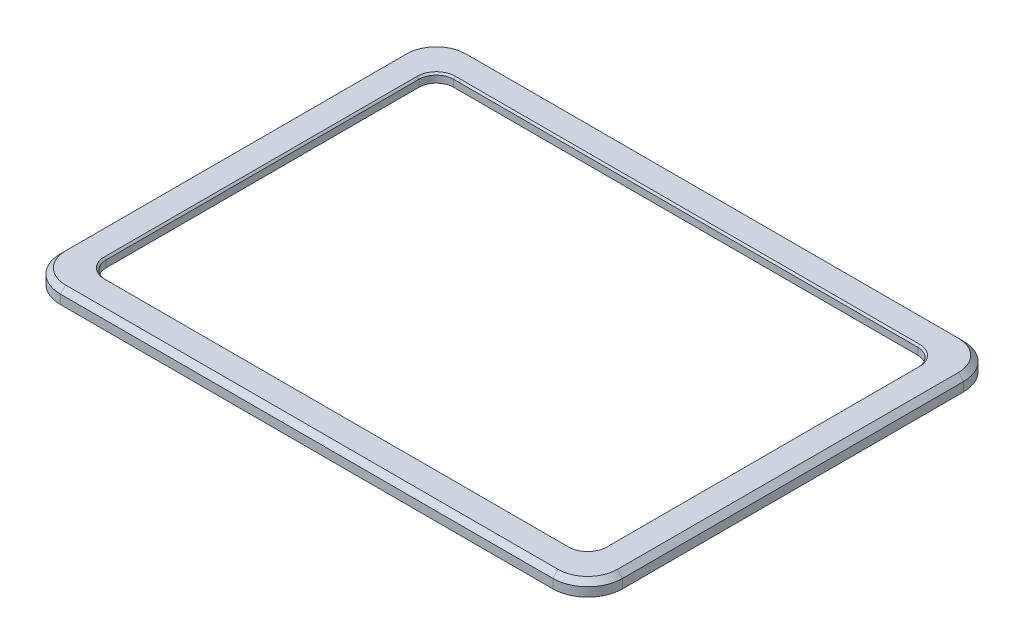
from build123d import *

# Parameters (mm, degrees)
SKETCH1_W                  = 323
SKETCH1_H                  = 236
SKETCH1_W_2                = 286.7
SKETCH1_H_2                = 199.7
BOSS_EXTRUDE1_DEPTH        = 5
SKETCH2_W                  = 323
SKETCH2_H                  = 236
SKETCH2_W_2                = 297.2
SKETCH2_H_2                = 210.2
BOSS_EXTRUDE2_DEPTH        = 3.2
FILLET1_R                  = 10
FILLET2_R                  = 20
M4_TAPPED_HOLE1_AT_2_COUNT = 2
M4_TAPPED_HOLE1_AT_2_PITCH = 66.8
M4_TAPPED_HOLE1_AT_3_COUNT = 2
M4_TAPPED_HOLE1_AT_3_PITCH = 133.6
M4_TAPPED_HOLE1_AT_4_COUNT = 2
M4_TAPPED_HOLE1_AT_4_PITCH = 200.4
M4_TAPPED_HOLE1_AT_5_COUNT = 2
M4_TAPPED_HOLE1_AT_5_PITCH = 267.2
M4_TAPPED_HOLE2_AT_2_COUNT = 2
M4_TAPPED_HOLE2_AT_2_PITCH = 45.05
M4_TAPPED_HOLE2_AT_3_COUNT = 2
M4_TAPPED_HOLE2_AT_3_PITCH = 90.1
M4_TAPPED_HOLE2_AT_4_COUNT = 2
M4_TAPPED_HOLE2_AT_4_PITCH = 135.15
M4_TAPPED_HOLE2_AT_5_COUNT = 2
M4_TAPPED_HOLE2_AT_5_PITCH = 180.2
CHAMFER2_SIZE              = 3
SKETCH7_R                  = 3
CUT_EXTRUDE1_DEPTH         = 3.2
FILLET3_R                  = 10
CHAMFER3_SIZE              = 1
CUT_EXTRUDE2_DEPTH         = 2
CUT_EXTRUDE3_DEPTH         = 2


with BuildPart() as part:
    # Sketch1 → Boss-Extrude1 (new body)
    with BuildSketch(Plane(origin=(0, 0, 0), x_dir=(1, 0, 0), z_dir=(0, 1, 0))):
        Rectangle(SKETCH1_W, SKETCH1_H)
        Rectangle(SKETCH1_W_2, SKETCH1_H_2, mode=Mode.SUBTRACT)
    extrude(amount=BOSS_EXTRUDE1_DEPTH)

    # Sketch2 → Boss-Extrude2 (add)
    with BuildSketch(Plane.XZ):
        Rectangle(SKETCH2_W, SKETCH2_H)
        Rectangle(SKETCH2_W_2, SKETCH2_H_2, mode=Mode.SUBTRACT)
    extrude(amount=BOSS_EXTRUDE2_DEPTH)

    # Fillet1
    fillet1_edges = [part.edges().sort_by_distance(p)[0] for p in [
        (-143.35, 2.5, 99.85),
        (143.35, 2.5, 99.85),
        (143.35, 2.5, -99.85),
        (-143.35, 2.5, -99.85),
    ]]
    fillet(fillet1_edges, radius=FILLET1_R)

    # Fillet2
    fillet2_edges = [part.edges().sort_by_distance(p)[0] for p in [
        (-161.5, 0.9, 118),
        (-161.5, 0.9, -118),
        (161.5, 0.9, -118),
        (161.5, 0.9, 118),
    ]]
    fillet(fillet2_edges, radius=FILLET2_R)

    # Sketch4 → M4 Tapped Hole1 (revolve, cut)
    with BuildSketch(Plane(origin=(133.6, -3.2, -109), x_dir=(0, 0, -1), z_dir=(1, 0, 0))):
        Polygon((0, 0), (0, 6.991420021), (1.65, 6), (1.65, 0), align=None)
    m4_tapped_hole1 = revolve(axis=Axis((133.6, -9.55, -109), (0, 1, 0)), mode=Mode.SUBTRACT)

    # M4 Tapped Hole1 at 2: M4 Tapped Hole1 ×2
    with Locations(*[(-i * M4_TAPPED_HOLE1_AT_2_PITCH, 0, 0) for i in range(1, M4_TAPPED_HOLE1_AT_2_COUNT)]):
        add(m4_tapped_hole1, mode=Mode.SUBTRACT)

    # M4 Tapped Hole1 at 3: M4 Tapped Hole1 ×2
    with Locations(*[(-i * M4_TAPPED_HOLE1_AT_3_PITCH, 0, 0) for i in range(1, M4_TAPPED_HOLE1_AT_3_COUNT)]):
        add(m4_tapped_hole1, mode=Mode.SUBTRACT)

    # M4 Tapped Hole1 at 4: M4 Tapped Hole1 ×2
    with Locations(*[(-i * M4_TAPPED_HOLE1_AT_4_PITCH, 0, 0) for i in range(1, M4_TAPPED_HOLE1_AT_4_COUNT)]):
        add(m4_tapped_hole1, mode=Mode.SUBTRACT)

    # M4 Tapped Hole1 at 5: M4 Tapped Hole1 ×2
    with Locations(*[(-i * M4_TAPPED_HOLE1_AT_5_PITCH, 0, 0) for i in range(1, M4_TAPPED_HOLE1_AT_5_COUNT)]):
        add(m4_tapped_hole1, mode=Mode.SUBTRACT)

    # Mirror1: M4 Tapped Hole1 across plane
    add(m4_tapped_hole1.mirror(Plane.XY), mode=Mode.SUBTRACT)

    # Mirror1 copy 1 sketch → Mirror1 copy 1 (revolve, cut)
    with BuildSketch(Plane(origin=(66.8, -3.2, 109), x_dir=(0, 0, 1), z_dir=(1, 0, 0))):
        Polygon((0, 0), (0, -6.991420021), (1.65, -6), (1.65, 0), align=None)
    revolve(axis=Axis((66.8, -9.55, 109), (0, -1, 0)), mode=Mode.SUBTRACT)

    # Mirror1 copy 2 sketch → Mirror1 copy 2 (revolve, cut)
    with BuildSketch(Plane(origin=(0, -3.2, 109), x_dir=(0, 0, 1), z_dir=(1, 0, 0))):
        Polygon((0, 0), (0, -6.991420021), (1.65, -6), (1.65, 0), align=None)
    revolve(axis=Axis((0, -9.55, 109), (0, -1, 0)), mode=Mode.SUBTRACT)

    # Mirror1 copy 3 sketch → Mirror1 copy 3 (revolve, cut)
    with BuildSketch(Plane(origin=(-66.8, -3.2, 109), x_dir=(0, 0, 1), z_dir=(1, 0, 0))):
        Polygon((0, 0), (0, -6.991420021), (1.65, -6), (1.65, 0), align=None)
    revolve(axis=Axis((-66.8, -9.55, 109), (0, -1, 0)), mode=Mode.SUBTRACT)

    # Mirror1 copy 4 sketch → Mirror1 copy 4 (revolve, cut)
    with BuildSketch(Plane(origin=(-133.6, -3.2, 109), x_dir=(0, 0, 1), z_dir=(1, 0, 0))):
        Polygon((0, 0), (0, -6.991420021), (1.65, -6), (1.65, 0), align=None)
    revolve(axis=Axis((-133.6, -9.55, 109), (0, -1, 0)), mode=Mode.SUBTRACT)

    # Sketch6 → M4 Tapped Hole2 (revolve, cut)
    with BuildSketch(Plane(origin=(152.5, -3.2, -90.1), x_dir=(0, 0, -1), z_dir=(1, 0, 0))):
        Polygon((0, 0), (0, 7.091420021), (1.65, 6.1), (1.65, 0), align=None)
    m4_tapped_hole2 = revolve(axis=Axis((152.5, -9.55, -90.1), (0, 1, 0)), mode=Mode.SUBTRACT)

    # M4 Tapped Hole2 at 2: M4 Tapped Hole2 ×2
    with Locations(*[(0, 0, i * M4_TAPPED_HOLE2_AT_2_PITCH) for i in range(1, M4_TAPPED_HOLE2_AT_2_COUNT)]):
        add(m4_tapped_hole2, mode=Mode.SUBTRACT)

    # M4 Tapped Hole2 at 3: M4 Tapped Hole2 ×2
    with Locations(*[(0, 0, i * M4_TAPPED_HOLE2_AT_3_PITCH) for i in range(1, M4_TAPPED_HOLE2_AT_3_COUNT)]):
        add(m4_tapped_hole2, mode=Mode.SUBTRACT)

    # M4 Tapped Hole2 at 4: M4 Tapped Hole2 ×2
    with Locations(*[(0, 0, i * M4_TAPPED_HOLE2_AT_4_PITCH) for i in range(1, M4_TAPPED_HOLE2_AT_4_COUNT)]):
        add(m4_tapped_hole2, mode=Mode.SUBTRACT)

    # M4 Tapped Hole2 at 5: M4 Tapped Hole2 ×2
    with Locations(*[(0, 0, i * M4_TAPPED_HOLE2_AT_5_PITCH) for i in range(1, M4_TAPPED_HOLE2_AT_5_COUNT)]):
        add(m4_tapped_hole2, mode=Mode.SUBTRACT)

    # Mirror2: M4 Tapped Hole2 across plane
    add(m4_tapped_hole2.mirror(Plane(origin=(0, 0, 0), x_dir=(0, 0, 1), z_dir=(1, 0, 0))), mode=Mode.SUBTRACT)

    # Mirror2 copy 1 sketch → Mirror2 copy 1 (revolve, cut)
    with BuildSketch(Plane(origin=(-152.5, -3.2, -45.05), x_dir=(0, 0, -1), z_dir=(-1, 0, 0))):
        Polygon((0, 0), (0, -7.091420021), (1.65, -6.1), (1.65, 0), align=None)
    revolve(axis=Axis((-152.5, -9.55, -45.05), (0, -1, 0)), mode=Mode.SUBTRACT)

    # Mirror2 copy 2 sketch → Mirror2 copy 2 (revolve, cut)
    with BuildSketch(Plane(origin=(-152.5, -3.2, 0), x_dir=(0, 0, -1), z_dir=(-1, 0, 0))):
        Polygon((0, 0), (0, -7.091420021), (1.65, -6.1), (1.65, 0), align=None)
    revolve(axis=Axis((-152.5, -9.55, 0), (0, -1, 0)), mode=Mode.SUBTRACT)

    # Mirror2 copy 3 sketch → Mirror2 copy 3 (revolve, cut)
    with BuildSketch(Plane(origin=(-152.5, -3.2, 45.05), x_dir=(0, 0, -1), z_dir=(-1, 0, 0))):
        Polygon((0, 0), (0, -7.091420021), (1.65, -6.1), (1.65, 0), align=None)
    revolve(axis=Axis((-152.5, -9.55, 45.05), (0, -1, 0)), mode=Mode.SUBTRACT)

    # Mirror2 copy 4 sketch → Mirror2 copy 4 (revolve, cut)
    with BuildSketch(Plane(origin=(-152.5, -3.2, 90.1), x_dir=(0, 0, -1), z_dir=(-1, 0, 0))):
        Polygon((0, 0), (0, -7.091420021), (1.65, -6.1), (1.65, 0), align=None)
    revolve(axis=Axis((-152.5, -9.55, 90.1), (0, -1, 0)), mode=Mode.SUBTRACT)

    # Chamfer2
    chamfer2_edges = [part.edges().sort_by_distance(p)[0] for p in [
        (0, 5, 118),
        (-161.5, 5, 0),
        (161.5, 5, 0),
        (0, 5, -118),
        (-155.642135624, 5, -112.142135624),
        (155.642135624, 5, 112.142135624),
        (155.642135624, 5, -112.142135624),
        (-155.642135624, 5, 112.142135624),
    ]]
    chamfer(chamfer2_edges, length=CHAMFER2_SIZE)

    # Sketch7 → Cut-Extrude1 (cut)
    with BuildSketch(Plane.XZ.offset(3.2)):
        with Locations((147.3, -103.8)):
            Circle(SKETCH7_R)
        with Locations((-147.3, -103.8)):
            Circle(SKETCH7_R)
        with Locations((-147.3, 103.8)):
            Circle(SKETCH7_R)
        with Locations((147.3, 103.8)):
            Circle(SKETCH7_R)
    extrude(amount=-CUT_EXTRUDE1_DEPTH, mode=Mode.SUBTRACT)

    # Fillet3
    fillet3_edges = [part.edges().sort_by_distance(p)[0] for p in [
        (144.596298833, -1.6, -105.1),
        (-144.596298833, -1.6, -105.1),
        (-148.6, -1.6, 101.096298833),
        (144.596298833, -1.6, 105.1),
        (148.6, -1.6, 101.096298833),
        (-144.596298833, -1.6, 105.1),
        (-148.6, -1.6, -101.096298833),
        (148.6, -1.6, -101.096298833),
    ]]
    fillet(fillet3_edges, radius=FILLET3_R)

    # Chamfer3
    chamfer3_edges = [part.edges().sort_by_distance(p)[0] for p in [
        (0, 5, 99.85),
        (143.35, 5, 0),
        (0, 5, -99.85),
        (-143.35, 5, 0),
        (140.421067812, 5, 96.921067812),
        (140.421067812, 5, -96.921067812),
        (-140.421067812, 5, 96.921067812),
        (-140.421067812, 5, -96.921067812),
    ]]
    chamfer(chamfer3_edges, length=CHAMFER3_SIZE)

    # Sketch8 → Cut-Extrude2 (cut)
    with BuildSketch(Plane.XZ):
        with BuildLine():
            Line((148.6, -89.85), (148.6, 89.85))
            ThreePointArc((148.6, 89.85), (144.133378413, 100.633378413), (133.35, 105.1))
            Line((133.35, 105.1), (-133.35, 105.1))
            ThreePointArc((-133.35, 105.1), (-144.133378413, 100.633378413), (-148.6, 89.85))
            Line((-148.6, 89.85), (-148.6, -89.85))
            ThreePointArc((-148.6, -89.85), (-144.133378413, -100.633378413), (-133.35, -105.1))
            Line((-133.35, -105.1), (133.35, -105.1))
            ThreePointArc((133.35, -105.1), (144.133378413, -100.633378413), (148.6, -89.85))
        make_face()
        with BuildLine():
            Line((133.35, 101.85), (-133.35, 101.85))
            ThreePointArc((-133.35, 101.85), (-141.835281374, 98.335281374), (-145.35, 89.85))
            Line((-145.35, 89.85), (-145.35, -89.85))
            ThreePointArc((-145.35, -89.85), (-141.835281374, -98.335281374), (-133.35, -101.85))
            Line((-133.35, -101.85), (133.35, -101.85))
            ThreePointArc((133.35, -101.85), (141.835281374, -98.335281374), (145.35, -89.85))
            Line((145.35, -89.85), (145.35, 89.85))
            ThreePointArc((145.35, 89.85), (141.835281374, 98.335281374), (133.35, 101.85))
        make_face(mode=Mode.SUBTRACT)
    extrude(amount=-CUT_EXTRUDE2_DEPTH, mode=Mode.SUBTRACT)

    # Sketch9 → Cut-Extrude3 (cut)
    with BuildSketch(Plane.XZ.offset(3.2)):
        with BuildLine():
            Line((141.5, 116), (-141.5, 116))
            ThreePointArc((-141.5, 116), (-154.227922061, 110.727922061), (-159.5, 98))
            Line((-159.5, 98), (-159.5, -98))
            ThreePointArc((-159.5, -98), (-154.227922061, -110.727922061), (-141.5, -116))
            Line((-141.5, -116), (141.5, -116))
            ThreePointArc((141.5, -116), (154.227922061, -110.727922061), (159.5, -98))
            Line((159.5, -98), (159.5, 98))
            ThreePointArc((159.5, 98), (154.227922061, 110.727922061), (141.5, 116))
        make_face()
        with BuildLine():
            Line((156.25, -98), (156.25, 98))
            ThreePointArc((156.25, 98), (151.929825023, 108.429825023), (141.5, 112.75))
            Line((141.5, 112.75), (-141.5, 112.75))
            ThreePointArc((-141.5, 112.75), (-151.929825023, 108.429825023), (-156.25, 98))
            Line((-156.25, 98), (-156.25, -98))
            ThreePointArc((-156.25, -98), (-151.929825023, -108.429825023), (-141.5, -112.75))
            Line((-141.5, -112.75), (141.5, -112.75))
            ThreePointArc((141.5, -112.75), (151.929825023, -108.429825023), (156.25, -98))
        make_face(mode=Mode.SUBTRACT)
    extrude(amount=-CUT_EXTRUDE3_DEPTH, mode=Mode.SUBTRACT)


solid = part.part
